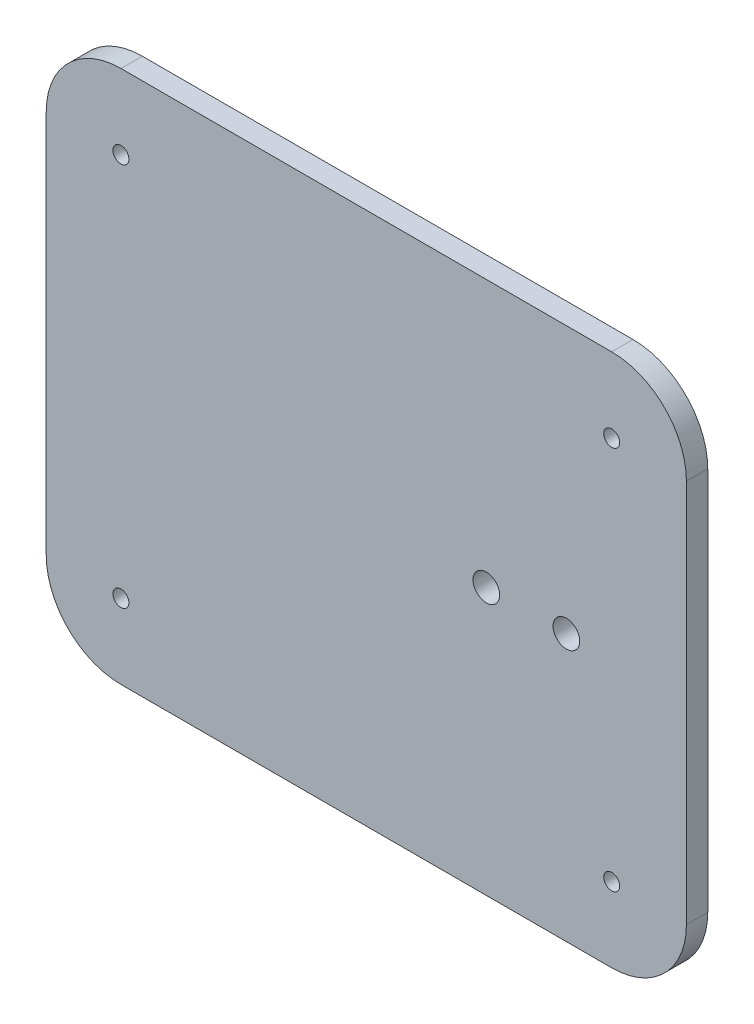
from build123d import *

# Parameters (mm, degrees)
SKETCH_1_W          = 120
SKETCH_1_H          = 100
EXTRUDE_1_DEPTH     = 4
FILLET_1_R          = 14
SKETCH_2_R          = 1.5
CUT_EXTRUDE_1_DEPTH = 5
SKETCH_7_R          = 2.5
CUT_EXTRUDE_2_DEPTH = 5


with BuildPart() as part:
    # 草图1 → 凸台-拉伸1 (new body)
    with BuildSketch(Plane.XY):
        with Locations((7.34439834, -11.161825726)):
            Rectangle(SKETCH_1_W, SKETCH_1_H)
    extrude(amount=EXTRUDE_1_DEPTH)

    # 圆角1
    fillet_1_edges = [part.edges().sort_by_distance(p)[0] for p in [
        (-52.65560166, 38.838174274, 2),
        (67.34439834, 38.838174274, 2),
        (67.34439834, -61.161825726, 2),
        (-52.65560166, -61.161825726, 2),
    ]]
    fillet(fillet_1_edges, radius=FILLET_1_R)

    # 草图2 → 切除-拉伸1 (cut, through all)
    with BuildSketch(Plane.XY.offset(4)):
        with Locations((53.34439834, 24.838174274)):
            Circle(SKETCH_2_R)
        with Locations((-38.65560166, 24.838174274)):
            Circle(SKETCH_2_R)
        with Locations((-38.65560166, -47.161825726)):
            Circle(SKETCH_2_R)
        with Locations((53.34439834, -47.161825726)):
            Circle(SKETCH_2_R)
    extrude(amount=-CUT_EXTRUDE_1_DEPTH, mode=Mode.SUBTRACT)

    # 草图7 → 切除-拉伸2 (cut, through all)
    with BuildSketch(Plane(origin=(0, 0, 0), x_dir=(-1, 0, 0), z_dir=(0, 0, -1))):
        with Locations((-44.84439834, -11.161825726)):
            Circle(SKETCH_7_R)
        with Locations((-29.84439834, -11.161825726)):
            Circle(SKETCH_7_R)
    extrude(amount=-CUT_EXTRUDE_2_DEPTH, mode=Mode.SUBTRACT)


solid = part.part
